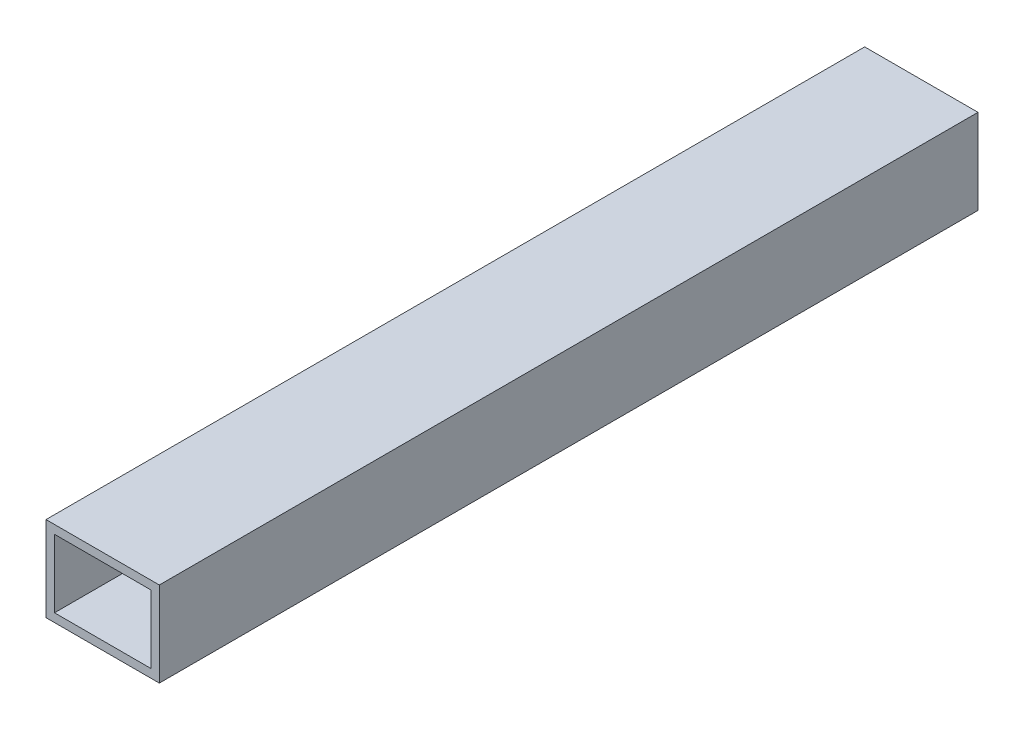
from build123d import *

# Parameters (mm, degrees)
CROQUIS1_W              = 289
CROQUIS1_H              = 30
SALIENTE_EXTRUIR1_DEPTH = 40
CROQUIS2_W              = 34
CROQUIS2_H              = 24
CORTAR_EXTRUIR1_DEPTH   = 890


with BuildPart() as part:
    # Croquis1 → Saliente-Extruir1 (new body)
    with BuildSketch(Plane(origin=(0, 0, 0), x_dir=(0, 0, -1), z_dir=(1, 0, 0))):
        Rectangle(CROQUIS1_W, CROQUIS1_H)
    extrude(amount=SALIENTE_EXTRUIR1_DEPTH)

    # Croquis2 → Cortar-Extruir1 (cut)
    with BuildSketch(Plane.XY.offset(144.5)):
        with Locations((20, 0)):
            Rectangle(CROQUIS2_W, CROQUIS2_H)
    extrude(amount=-CORTAR_EXTRUIR1_DEPTH, mode=Mode.SUBTRACT)


solid = part.part
